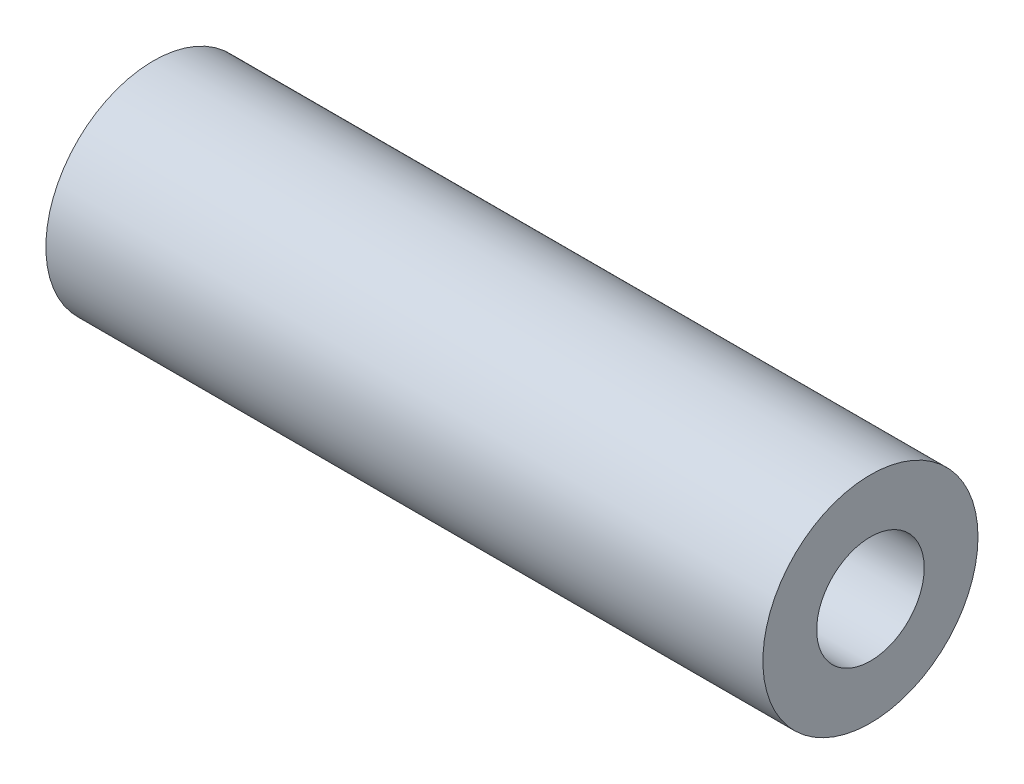
from build123d import *

# Parameters (mm, degrees)
SKETCH1_R           = 19.05
SKETCH1_R_2         = 9.525
BOSS_EXTRUDE1_DEPTH = 63.5


with BuildPart() as part:
    # Sketch1 → Boss-Extrude1 (new body, symmetric)
    with BuildSketch(Plane(origin=(0, 0, 0), x_dir=(0, 0, -1), z_dir=(1, 0, 0))):
        Circle(SKETCH1_R)
        Circle(SKETCH1_R_2, mode=Mode.SUBTRACT)
    extrude(amount=BOSS_EXTRUDE1_DEPTH, both=True)


solid = part.part
